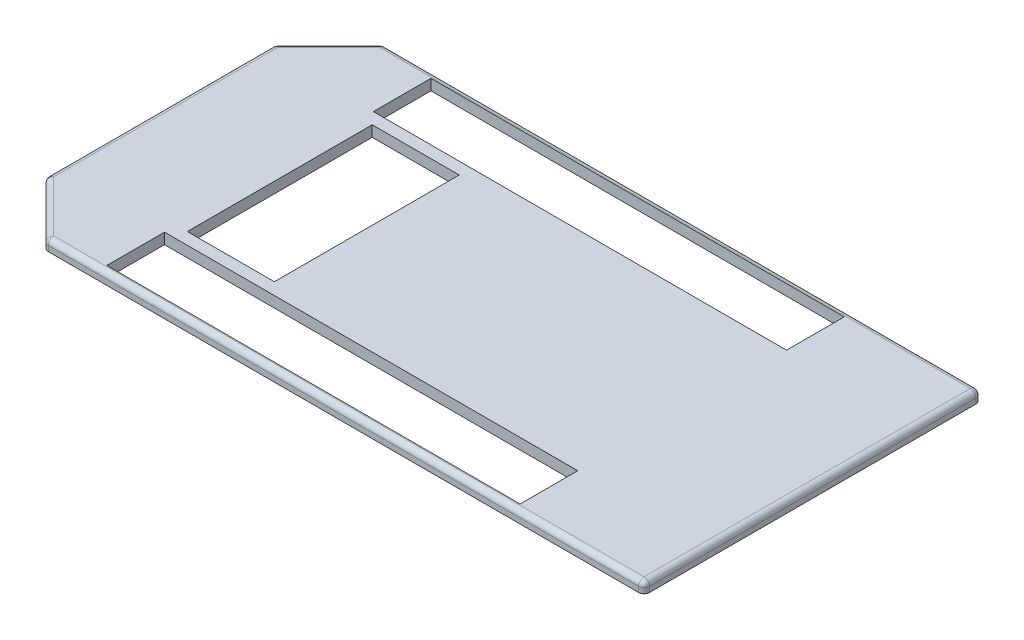
from build123d import *

# Parameters (mm, degrees)
BOSS_EXTRUDE2_DEPTH = 10
FILLET1_R           = 5
SKETCH7_W           = 380
SKETCH7_H           = 53
SKETCH7_W_2         = 80
SKETCH7_H_2         = 170
CUT_EXTRUDE1_DEPTH  = 10


with BuildPart() as part:
    # Sketch1 → Boss-Extrude2 (new body)
    with BuildSketch(Plane(origin=(0, 0, 0), x_dir=(1, 0, 0), z_dir=(0, 1, 0))):
        Polygon((-300, 105), (-250, 155), (300, 155), (300, -155), (-250, -155), (-300, -105), align=None)
    extrude(amount=BOSS_EXTRUDE2_DEPTH)

    # Fillet1
    fillet1_edges = [part.edges().sort_by_distance(p)[0] for p in [
        (300, 5, 155),
        (-250, 5, 155),
        (-300, 5, 105),
        (-300, 5, -105),
        (-250, 5, -155),
        (300, 5, -155),
        (-275, 10, -130),
        (-300, 10, 0),
        (-275, 10, 130),
        (25, 10, 155),
        (300, 10, 0),
        (25, 10, -155),
    ]]
    fillet(fillet1_edges, radius=FILLET1_R)

    # Sketch7 → Cut-Extrude1 (cut)
    with BuildSketch(Plane.XZ):
        with Locations((-10, -122.5)):
            Rectangle(SKETCH7_W, SKETCH7_H)
        with Locations((-10, 122.5)):
            Rectangle(SKETCH7_W, SKETCH7_H)
        with Locations((-150, 0)):
            Rectangle(SKETCH7_W_2, SKETCH7_H_2)
    extrude(amount=-CUT_EXTRUDE1_DEPTH, mode=Mode.SUBTRACT)


solid = part.part
